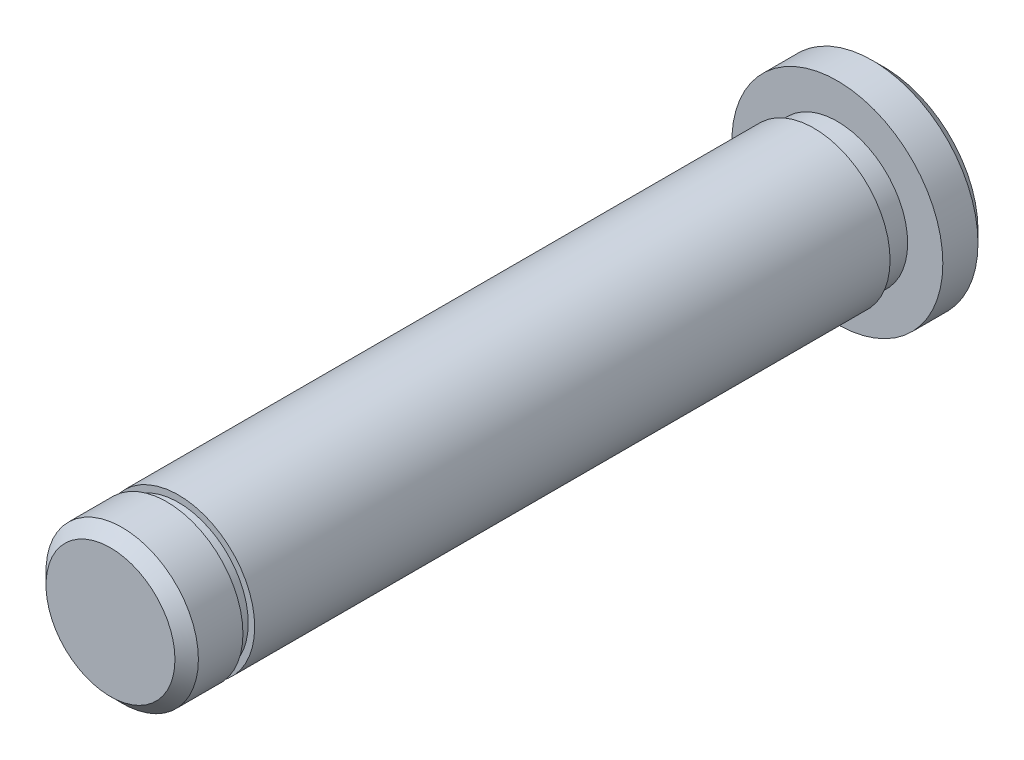
from build123d import *

# Parameters (mm, degrees)
SKETCH_1_R          = 9
EXTRUDE_1_DEPTH     = 4
SKETCH_2_R          = 6.5
EXTRUDE_2_DEPTH     = 62
SKETCH_4_OUTSIDE_W  = 34.148
SKETCH_4_OUTSIDE_H  = 34.148
SKETCH_4_OUTSIDE_R  = 6
CUT_EXTRUDE_1_DEPTH = 2
CUT_EXTRUDE_START   = -5.8
SKETCH_5_OUTSIDE_W  = 34.148
SKETCH_5_OUTSIDE_H  = 34.148
SKETCH_5_OUTSIDE_R  = 5.95
CUT_EXTRUDE_2_DEPTH = 1
CHAMFER_1_SIZE      = 1


with BuildPart() as part:
    # 草图1 → 凸台-拉伸1 (new body)
    with BuildSketch(Plane.XY):
        Circle(SKETCH_1_R)
    extrude(amount=EXTRUDE_1_DEPTH)

    # 草图2 → 凸台-拉伸2 (add)
    with BuildSketch(Plane.XY.offset(4)):
        Circle(SKETCH_2_R)
    extrude(amount=EXTRUDE_2_DEPTH)

    # 草图4 outside → 切除-拉伸1 (cut)
    with BuildSketch(Plane.XY.offset(4)):
        Rectangle(SKETCH_4_OUTSIDE_W, SKETCH_4_OUTSIDE_H)
        Circle(SKETCH_4_OUTSIDE_R, mode=Mode.SUBTRACT)
    extrude(amount=CUT_EXTRUDE_1_DEPTH, mode=Mode.SUBTRACT)

    # 草图5 outside → 切除-拉伸2 (cut)
    with BuildSketch(Plane.XY.offset(66).offset(CUT_EXTRUDE_START)):
        Rectangle(SKETCH_5_OUTSIDE_W, SKETCH_5_OUTSIDE_H)
        Circle(SKETCH_5_OUTSIDE_R, mode=Mode.SUBTRACT)
    extrude(amount=CUT_EXTRUDE_2_DEPTH, mode=Mode.SUBTRACT)

    # 倒角1
    chamfer_1_edges = [part.edges().sort_by_distance(p)[0] for p in [
        (-9, 0, 0),
        (-6.5, 0, 66),
    ]]
    chamfer(chamfer_1_edges, length=CHAMFER_1_SIZE)


solid = part.part
